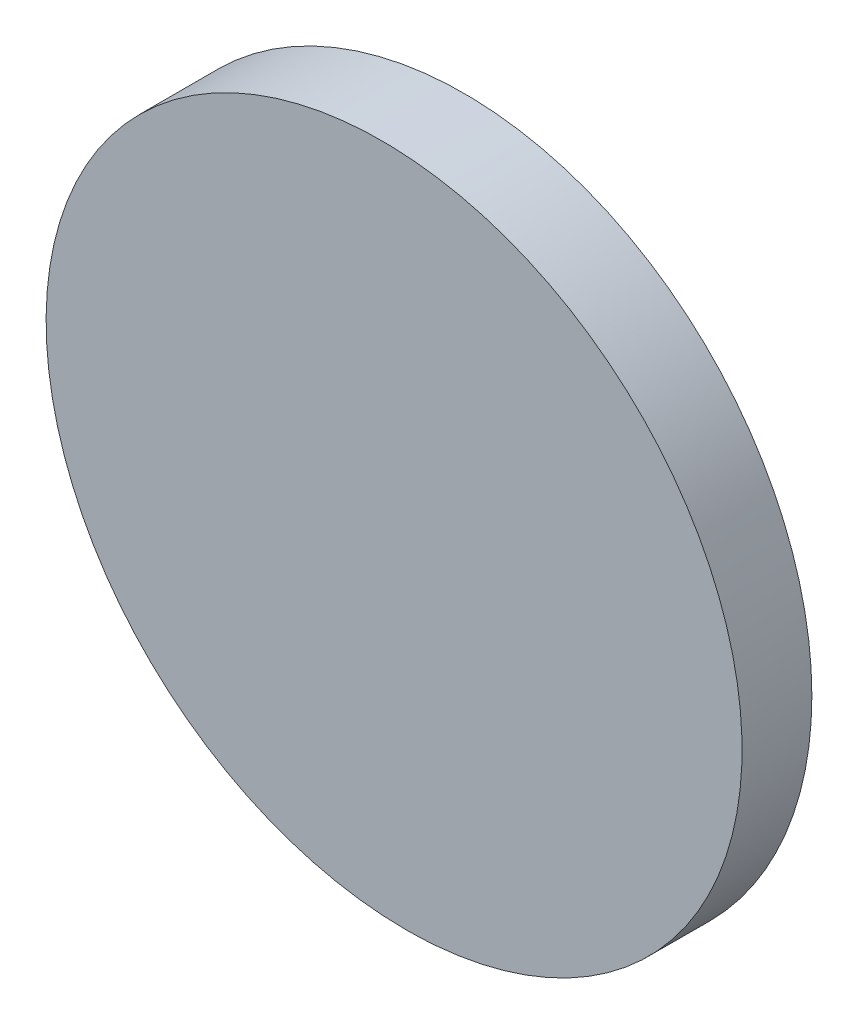
from build123d import *

# Parameters (mm, degrees)
SKETCH_2_R          = 25.4
EXTRUDE_1_DEPTH     = 6
CUT_EXTRUDE_1_DEPTH = 50


with BuildPart() as part:
    # 草图2 → 凸台-拉伸1 (new body)
    with BuildSketch(Plane.XY):
        Circle(SKETCH_2_R)
    extrude(amount=EXTRUDE_1_DEPTH)

    # 草图3 → 切除-拉伸1 (cut, symmetric)
    with BuildSketch(Plane(origin=(0, 0, 0), x_dir=(0, 0, -1), z_dir=(1, 0, 0))):
        Polygon((-6, -25.431677595), (-4.224918704, -25.431677595), (-6, 25.4), align=None)
    extrude(amount=CUT_EXTRUDE_1_DEPTH, both=True, mode=Mode.SUBTRACT)


solid = part.part
